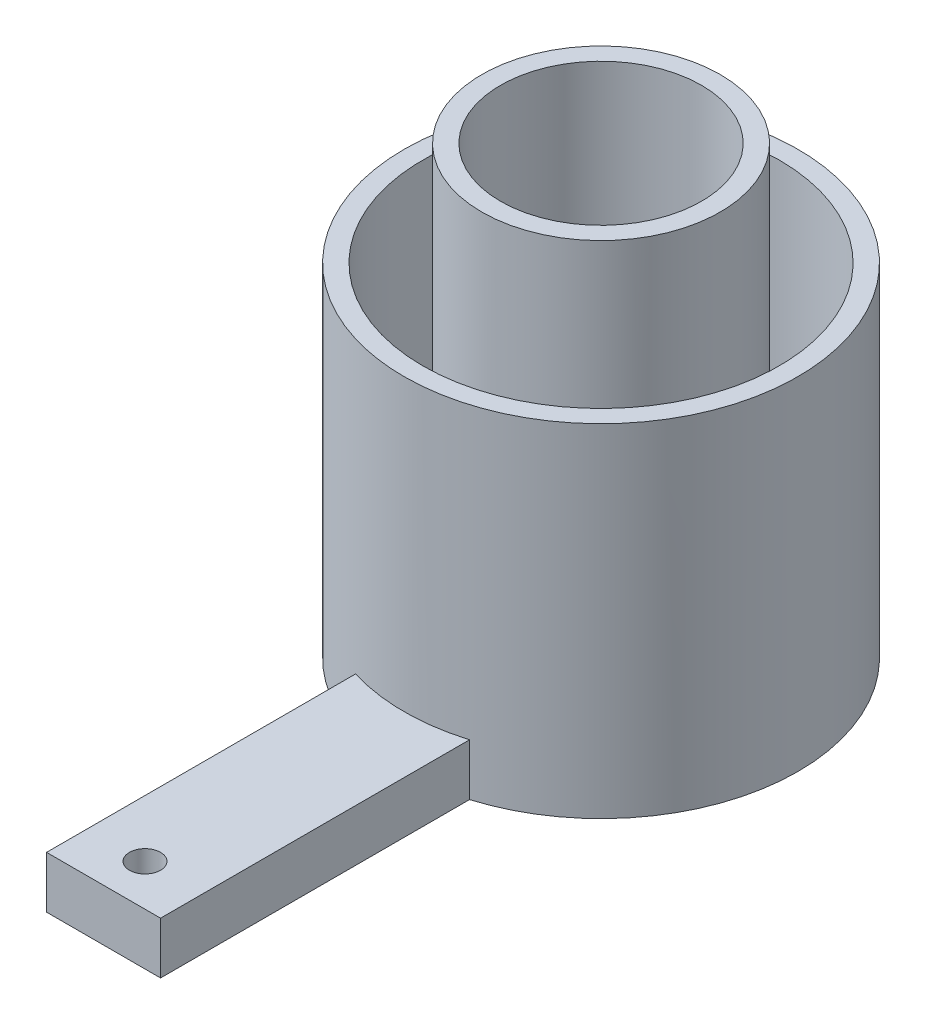
from build123d import *

# Parameters (mm, degrees)
SKETCH1_R           = 19
SKETCH1_R_2         = 17.2
BOSS_EXTRUDE1_DEPTH = 33
SKETCH1_3_R         = 11.5
SKETCH1_3_R_2       = 9.7
BOSS_EXTRUDE2_DEPTH = 43
SKETCH2_R           = 17.2
BOSS_EXTRUDE3_DEPTH = 3
BOSS_EXTRUDE4_DEPTH = 2.4
BOSS_EXTRUDE5_DEPTH = 5
SKETCH5_R           = 1.5
CUT_EXTRUDE1_DEPTH  = 44


with BuildPart() as part:
    # Sketch1 → Boss-Extrude1 (new body)
    with BuildSketch(Plane(origin=(0, 0, 0), x_dir=(1, 0, 0), z_dir=(0, 1, 0))):
        Circle(SKETCH1_R)
        Circle(SKETCH1_R_2, mode=Mode.SUBTRACT)
    extrude(amount=BOSS_EXTRUDE1_DEPTH)



with BuildPart() as body_2:
    # Sketch1_3 → Boss-Extrude2 (new body)
    with BuildSketch(Plane(origin=(0, 0, 0), x_dir=(1, 0, 0), z_dir=(0, 1, 0))):
        Circle(SKETCH1_3_R)
        Circle(SKETCH1_3_R_2, mode=Mode.SUBTRACT)
    extrude(amount=BOSS_EXTRUDE2_DEPTH)


with BuildPart() as part_1:
    add(part.part)

    add(body_2.part)  # Boss-Extrude3 merges body 2
    # Sketch2 → Boss-Extrude3 (add)
    with BuildSketch(Plane(origin=(0, 10, 0), x_dir=(-1, 0, 0), z_dir=(0, -1, 0))):
        Circle(SKETCH2_R)
    extrude(amount=-BOSS_EXTRUDE3_DEPTH)

    # Sketch3 → Boss-Extrude4 (add)
    with BuildSketch(Plane.XZ):
        with BuildLine():
            Line((-14.921917905, -11.7616481), (-5.15253427, -5.060203124))
            Line((-5.15253427, -5.060203124), (-3.565454801, -6.280270465))
            Line((-3.565454801, -6.280270465), (-7.530041661, -17.444152963))
            ThreePointArc((-7.530041661, -17.444152963), (-11.579954122, -15.063354956), (-14.921917905, -11.7616481))
        make_face()
    extrude(amount=-BOSS_EXTRUDE4_DEPTH)

    # Sketch4 → Boss-Extrude5 (add)
    with BuildSketch(Plane.XZ):
        with BuildLine():
            Line((-5.5, 16.296932227), (-5.5, 10.099504938))
            ThreePointArc((-5.5, 10.099504938), (0, 11.5), (5.5, 10.099504938))
            Line((5.5, 10.099504938), (5.5, 16.296932227))
            ThreePointArc((5.5, 16.296932227), (0, 17.2), (-5.5, 16.296932227))
        make_face()
        with BuildLine():
            Line((-5.5, 18.186533479), (-5.5, 16.296932227))
            ThreePointArc((-5.5, 16.296932227), (0, 17.2), (5.5, 16.296932227))
            Line((5.5, 16.296932227), (5.5, 18.186533479))
            ThreePointArc((5.5, 18.186533479), (0, 19), (-5.5, 18.186533479))
        make_face()
        with BuildLine():
            Line((-5.5, 48), (-5.5, 18.186533479))
            ThreePointArc((-5.5, 18.186533479), (0, 19), (5.5, 18.186533479))
            Line((5.5, 18.186533479), (5.5, 48))
            Line((5.5, 48), (-5.5, 48))
        make_face()
        with BuildLine():
            Line((-5.5, 10.099504938), (-5.5, 7.989993742))
            ThreePointArc((-5.5, 7.989993742), (0, 9.7), (5.5, 7.989993742))
            Line((5.5, 7.989993742), (5.5, 10.099504938))
            ThreePointArc((5.5, 10.099504938), (0, 11.5), (-5.5, 10.099504938))
        make_face()
    extrude(amount=-BOSS_EXTRUDE5_DEPTH)

    # Sketch5 → Cut-Extrude1 (cut, through all)
    with BuildSketch(Plane.XZ):
        with Locations((0, 44)):
            Circle(SKETCH5_R)
    extrude(amount=-CUT_EXTRUDE1_DEPTH, mode=Mode.SUBTRACT)


solid = part_1.part
